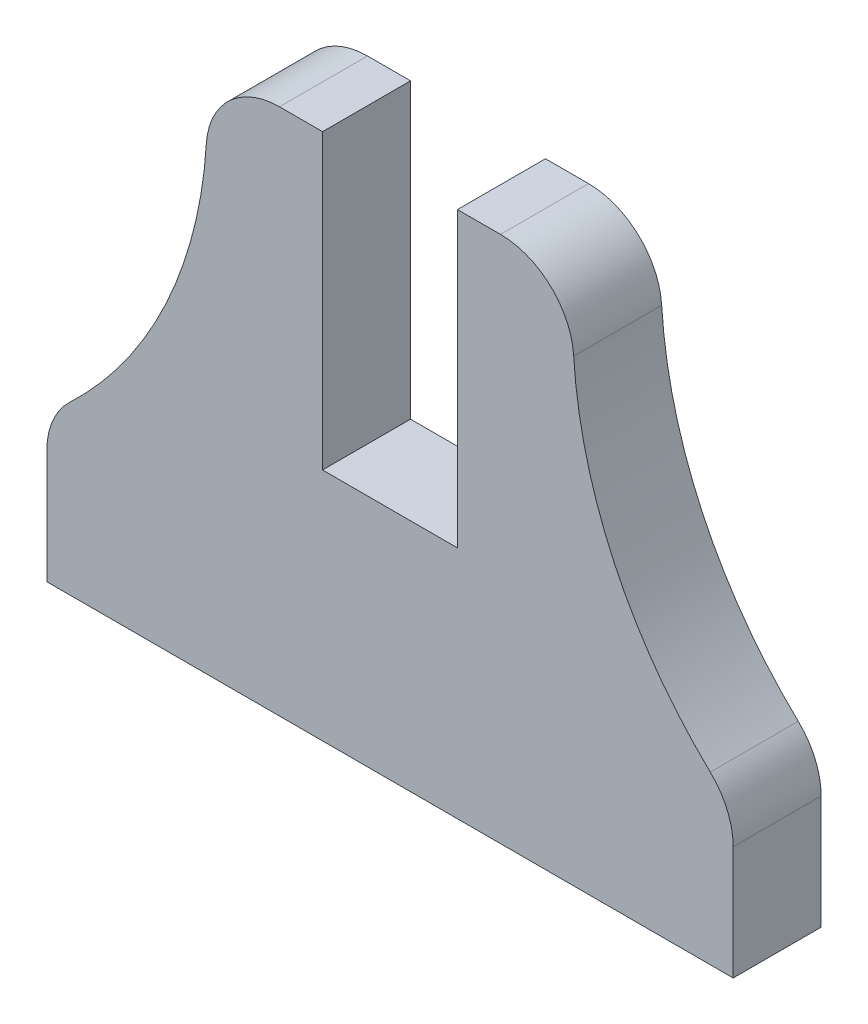
from build123d import *

# Parameters (mm, degrees)
BOSS_EXTRUDE1_DEPTH = 3


with BuildPart() as part:
    # Sketch1 → Boss-Extrude1 (new body)
    with BuildSketch(Plane.XY):
        with BuildLine():
            Line((-4.3, -163.694308418), (-4.3, -173.684305639))
            Line((-4.3, -173.684305639), (0.3, -173.684305639))
            Line((0.3, -173.684305639), (0.3, -163.694308418))
            Line((0.3, -163.694308418), (1.767652512, -163.694308418))
            ThreePointArc((1.767652512, -163.694308418), (3.479450891, -164.372291319), (4.262793246, -166.038511371))
            ThreePointArc((4.262793246, -166.038511371), (5.64620009, -171.458376258), (8.919091092, -175.994556853))
            ThreePointArc((8.919091092, -175.994556853), (9.496489466, -176.821698794), (9.7, -177.809694813))
            Line((9.7, -177.809694813), (9.7, -181.684305639))
            Line((9.7, -181.684305639), (-0.3, -181.684305639))
            Line((-0.3, -181.684305639), (-3.7, -181.684305639))
            Line((-3.7, -181.684305639), (-13.7, -181.684305639))
            Line((-13.7, -181.684305639), (-13.7, -177.809694813))
            ThreePointArc((-13.7, -177.809694813), (-13.496489466, -176.821698794), (-12.919091092, -175.994556853))
            ThreePointArc((-12.919091092, -175.994556853), (-9.64620009, -171.458376258), (-8.262793246, -166.038511371))
            ThreePointArc((-8.262793246, -166.038511371), (-7.479450891, -164.372291319), (-5.767652512, -163.694308418))
            Line((-5.767652512, -163.694308418), (-4.3, -163.694308418))
        make_face()
    extrude(amount=BOSS_EXTRUDE1_DEPTH)


solid = part.part
